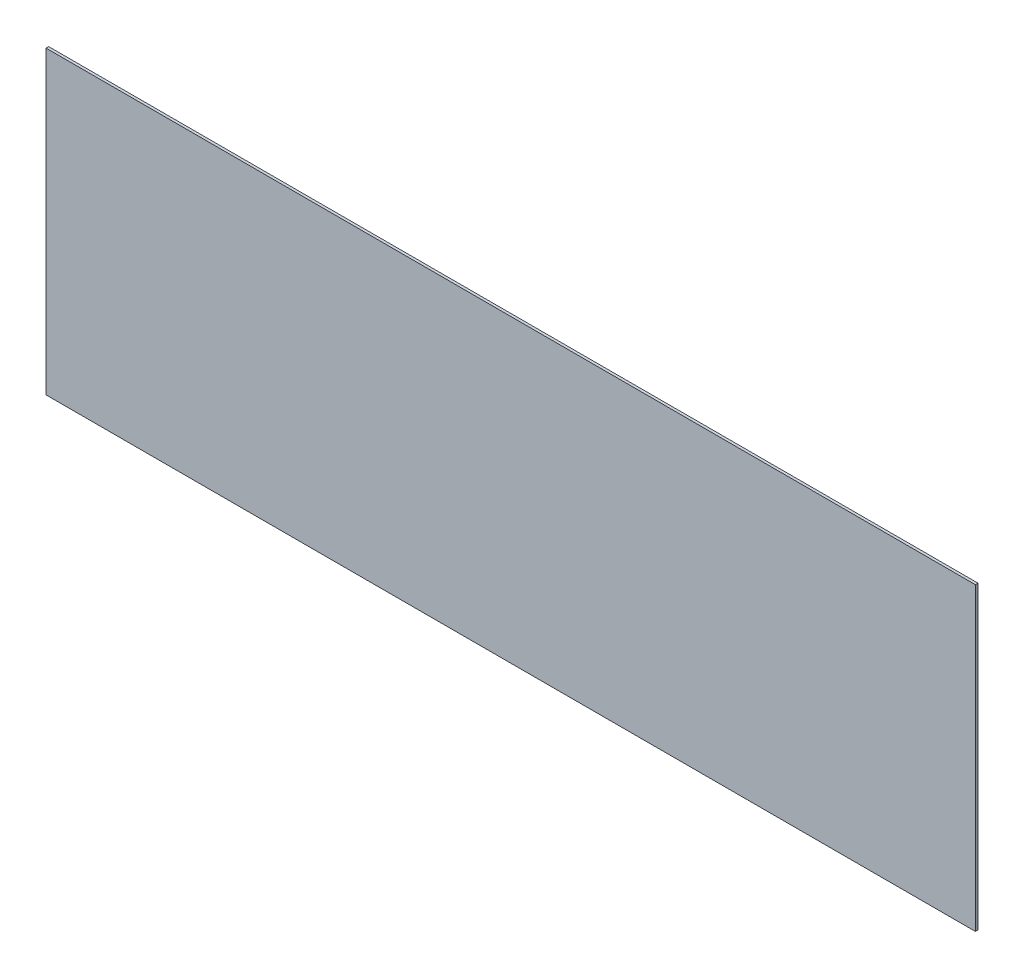
from build123d import *

# Parameters (mm, degrees)
SKETCH1_W           = 44.704
SKETCH1_H           = 14.44625
BOSS_EXTRUDE1_DEPTH = 0.127


with BuildPart() as part:
    # Sketch1 → Boss-Extrude1 (new body)
    with BuildSketch(Plane.XY):
        with Locations((39.37, -165.5922297)):
            Rectangle(SKETCH1_W, SKETCH1_H)
    extrude(amount=BOSS_EXTRUDE1_DEPTH)


solid = part.part
